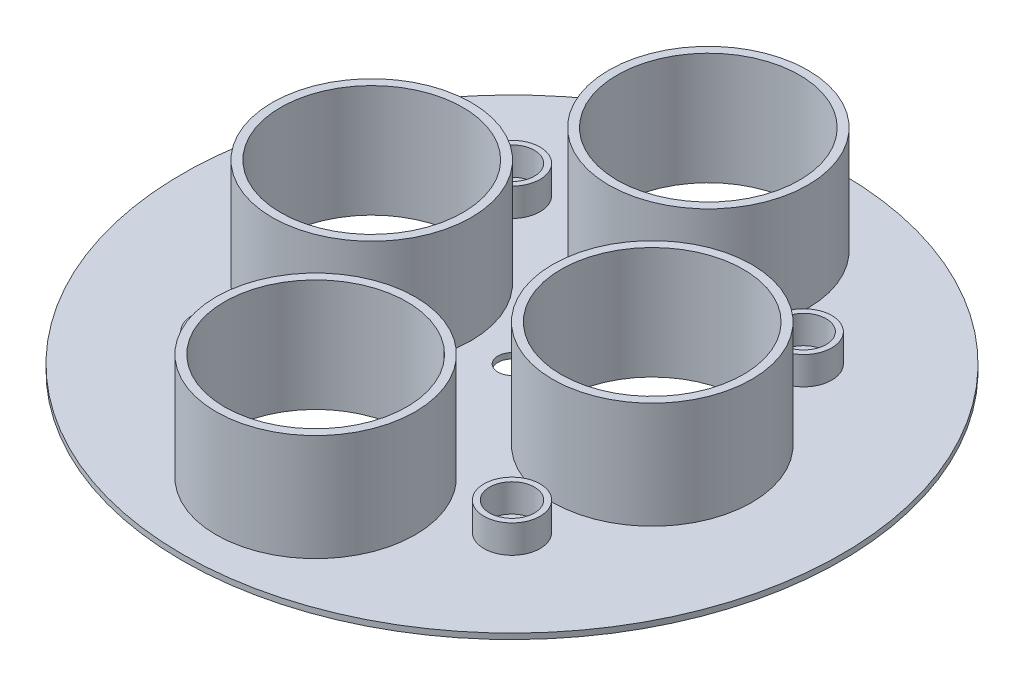
from build123d import *

# Parameters (mm, degrees)
IZIM1_R                     = 117.5
IZIM1_R_2                   = 32.5
IZIM1_R_3                   = 5
Y_KSEKLIK_EKSTR_ZYON1_DEPTH = 2
IZIM1_2_R                   = 35.5
IZIM1_2_R_2                 = 32.5
EKSTR_ZYON_NCE1_DEPTH       = 40
IZIM2_R                     = 10
IZIM2_R_2                   = 8
EKSTR_ZYON_NCE2_DEPTH       = 10


with BuildPart() as part:
    # Çizim1 → Yükseklik-Ekstrüzyon1 (new body)
    with BuildSketch(Plane(origin=(0, 0, 0), x_dir=(1, 0, 0), z_dir=(0, 1, 0))):
        Circle(IZIM1_R)
        with Locations((0, 70)):
            Circle(IZIM1_R_2, mode=Mode.SUBTRACT)
        with Locations((50, 0)):
            Circle(IZIM1_R_2, mode=Mode.SUBTRACT)
        with Locations((0, -70)):
            Circle(IZIM1_R_2, mode=Mode.SUBTRACT)
        with Locations((-50, 0)):
            Circle(IZIM1_R_2, mode=Mode.SUBTRACT)
        Circle(IZIM1_R_3, mode=Mode.SUBTRACT)
    extrude(amount=Y_KSEKLIK_EKSTR_ZYON1_DEPTH)

    # Çizim1<2> → Ekstrüzyon-İnce1 (add)
    with BuildSketch(Plane(origin=(0, 0, 0), x_dir=(1, 0, 0), z_dir=(0, 1, 0))):
        with Locations((0, 70)):
            Circle(IZIM1_2_R)
        with Locations((0, 70)):
            Circle(IZIM1_2_R_2, mode=Mode.SUBTRACT)
        with Locations((50, 0)):
            Circle(IZIM1_2_R)
        with Locations((50, 0)):
            Circle(IZIM1_2_R_2, mode=Mode.SUBTRACT)
        with Locations((0, -70)):
            Circle(IZIM1_2_R)
        with Locations((0, -70)):
            Circle(IZIM1_2_R_2, mode=Mode.SUBTRACT)
        with Locations((-50, 0)):
            Circle(IZIM1_2_R)
        with Locations((-50, 0)):
            Circle(IZIM1_2_R_2, mode=Mode.SUBTRACT)
    extrude(amount=EKSTR_ZYON_NCE1_DEPTH)

    # Çizim2 → Ekstrüzyon-İnce2 (add)
    with BuildSketch(Plane(origin=(0, 2, 0), x_dir=(1, 0, 0), z_dir=(0, 1, 0))):
        with Locations((52, -52)):
            Circle(IZIM2_R)
        with Locations((52, -52)):
            Circle(IZIM2_R_2, mode=Mode.SUBTRACT)
        with Locations((-52, -52)):
            Circle(IZIM2_R)
        with Locations((-52, -52)):
            Circle(IZIM2_R_2, mode=Mode.SUBTRACT)
        with Locations((-52, 52)):
            Circle(IZIM2_R)
        with Locations((-52, 52)):
            Circle(IZIM2_R_2, mode=Mode.SUBTRACT)
        with Locations((52, 52)):
            Circle(IZIM2_R)
        with Locations((52, 52)):
            Circle(IZIM2_R_2, mode=Mode.SUBTRACT)
    extrude(amount=EKSTR_ZYON_NCE2_DEPTH)


solid = part.part
